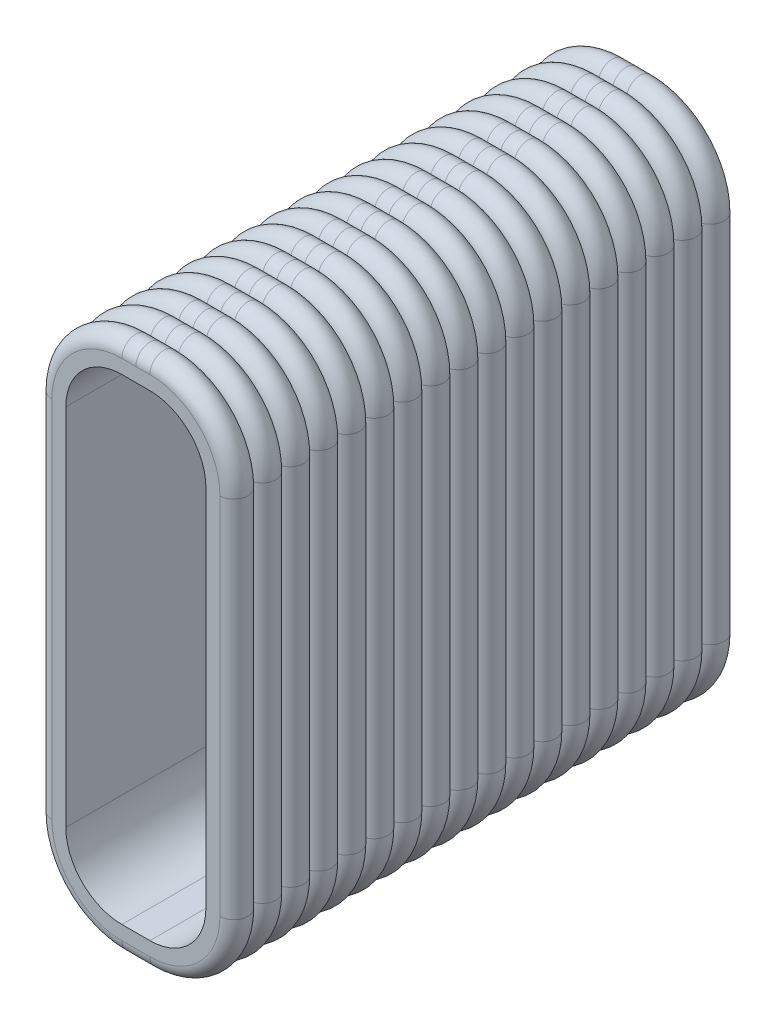
from build123d import *

# Parameters (mm, degrees)
BOSS_EXTRUDE1_DEPTH = 9
LPATTERN1_COUNT     = 18
LPATTERN1_PITCH     = 0.5


with BuildPart() as part:
    # Sketch1 → Boss-Extrude1 (new body)
    with BuildSketch(Plane.XY):
        with BuildLine():
            Line((-1.75, 3.25), (-1.75, -3.25))
            ThreePointArc((-1.75, -3.25), (-1.310660172, -4.310660172), (-0.25, -4.75))
            Line((-0.25, -4.75), (0.25, -4.75))
            ThreePointArc((0.25, -4.75), (1.310660172, -4.310660172), (1.75, -3.25))
            Line((1.75, -3.25), (1.75, 3.25))
            ThreePointArc((1.75, 3.25), (1.310660172, 4.310660172), (0.25, 4.75))
            Line((0.25, 4.75), (-0.25, 4.75))
            ThreePointArc((-0.25, 4.75), (-1.310660172, 4.310660172), (-1.75, 3.25))
        make_face()
        with BuildLine():
            Line((-0.25, 4.25), (0.25, 4.25))
            ThreePointArc((0.25, 4.25), (0.957106781, 3.957106781), (1.25, 3.25))
            Line((1.25, 3.25), (1.25, -3.25))
            ThreePointArc((1.25, -3.25), (0.957106781, -3.957106781), (0.25, -4.25))
            Line((0.25, -4.25), (-0.25, -4.25))
            ThreePointArc((-0.25, -4.25), (-0.957106781, -3.957106781), (-1.25, -3.25))
            Line((-1.25, -3.25), (-1.25, 3.25))
            ThreePointArc((-1.25, 3.25), (-0.957106781, 3.957106781), (-0.25, 4.25))
        make_face(mode=Mode.SUBTRACT)
    extrude(amount=-BOSS_EXTRUDE1_DEPTH)

    # Cut-Sweep3: sweep along a path in Sketch3
    with BuildLine(Plane.XY) as cut_sweep3_path:
        Line((0.25, 4.75), (-0.25, 4.75))
        ThreePointArc((-0.25, 4.75), (-1.310660172, 4.310660172), (-1.75, 3.25))
        Line((-1.75, 3.25), (-1.75, -3.25))
        ThreePointArc((-1.75, -3.25), (-1.310660172, -4.310660172), (-0.25, -4.75))
        Line((-0.25, -4.75), (0.25, -4.75))
        ThreePointArc((0.25, -4.75), (1.310660172, -4.310660172), (1.75, -3.25))
        Line((1.75, -3.25), (1.75, 3.25))
        ThreePointArc((1.75, 3.25), (1.310660172, 4.310660172), (0.25, 4.75))
    # Sketch2 → Cut-Sweep3 (sweep, cut)
    with BuildSketch(Plane(origin=(0, 0, 0), x_dir=(0, 0, -1), z_dir=(1, 0, 0))):
        with BuildLine():
            Line((0.5, 4.75), (0.5, 4.5))
            ThreePointArc((0.5, 4.5), (0.25, 4.75), (0, 4.5))
            Line((0, 4.5), (0, 4.75))
            Line((0, 4.75), (0, 5.25))
            Line((0, 5.25), (0.5, 5.25))
            Line((0.5, 5.25), (0.5, 4.75))
        make_face()
    cut_sweep3 = sweep(path=cut_sweep3_path.line, mode=Mode.SUBTRACT)

    # LPattern1: Cut-Sweep3 ×18
    with Locations(*[(0, 0, -i * LPATTERN1_PITCH) for i in range(1, LPATTERN1_COUNT)]):
        add(cut_sweep3, mode=Mode.SUBTRACT)


solid = part.part
